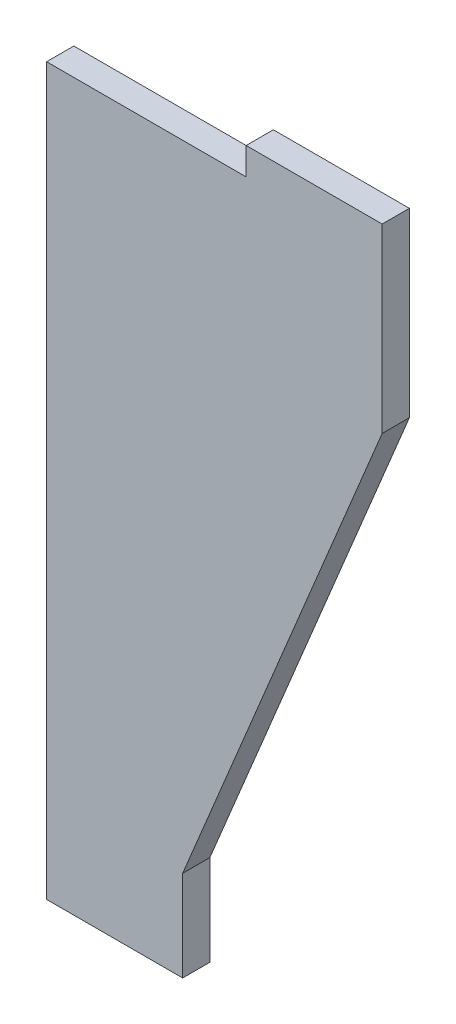
from build123d import *

# Parameters (mm, degrees)
EXTRUDE_1_DEPTH = 3


with BuildPart() as part:
    # 草图1 → 凸台-拉伸1 (new body)
    with BuildSketch(Plane.XY):
        Polygon((0, -80), (15, -80), (15, -70), (37, -17), (37, 3), (22, 3), (22, 0), (0, 0), align=None)
    extrude(amount=-EXTRUDE_1_DEPTH)


solid = part.part
